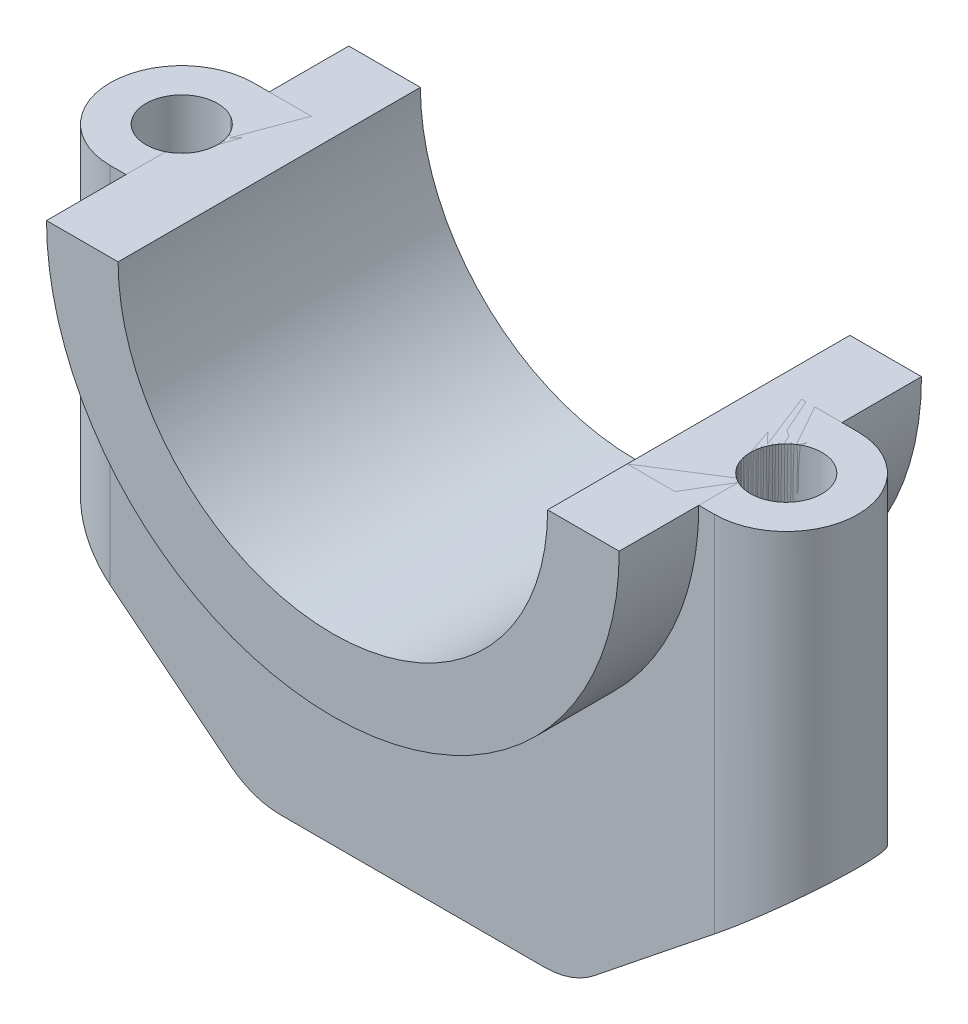
from build123d import *
from build123d.topology import SkipClean

# Parameters (mm, degrees)
BOSS_EXTRUDE1_DEPTH = 9
BOSS_EXTRUDE2_DEPTH = 19
SKETCH3_R           = 4.5
CUT_EXTRUDE1_DEPTH  = 60
CUT_EXTRUDE2_DEPTH  = 60
BOSS_EXTRUDE4_DEPTH = 60
CUT_EXTRUDE3_DEPTH  = 30
FILLET1_R           = 10


with BuildPart() as part:
    # Sketch1 → Boss-Extrude1 (new, symmetric)
    with BuildSketch(Plane.XY):
        with BuildLine():
            Line((-45.092177379, 0), (-45.092177379, -40))
            Line((-45.092177379, -40), (-20.092177379, -60))
            Line((-20.092177379, -60), (20.092177379, -60))
            Line((20.092177379, -60), (45.092177379, -40))
            Line((45.092177379, -40), (45.092177379, 0))
            Line((45.092177379, 0), (27, 0))
            ThreePointArc((27, 0), (0, -27), (-27, 0))
            Line((-27, 0), (-45.092177379, 0))
        make_face()
    extrude(amount=BOSS_EXTRUDE1_DEPTH, both=True)


with BuildPart() as body_2:
    # Sketch1_4 → Boss-Extrude2 (new, symmetric)
    with BuildSketch(Plane.XY):
        with BuildLine():
            Line((-27, 0), (-36, 0))
            ThreePointArc((-36, 0), (0, -36), (36, 0))
            Line((36, 0), (27, 0))
            ThreePointArc((27, 0), (0, -27), (-27, 0))
        make_face()
    extrude(amount=BOSS_EXTRUDE2_DEPTH, both=True)


with BuildPart() as cut_extrude1_tool:
    # Sketch3 → Cut-Extrude1 (new body)
    with BuildSketch(Plane(origin=(0, 0, 0), x_dir=(1, 0, 0), z_dir=(0, 1, 0))):
        with Locations((-38, 0)):
            Circle(SKETCH3_R)
        with Locations((38, 0)):
            Circle(SKETCH3_R)
    extrude(amount=-CUT_EXTRUDE1_DEPTH)


with BuildPart() as part_1:
    add(part.part)

    # Cut-Extrude1: cut by cut_extrude1_tool
    add(cut_extrude1_tool.part, mode=Mode.SUBTRACT)

    # Sketch3_4 → Cut-Extrude2 (cut)
    with BuildSketch(Plane(origin=(0, 0, 0), x_dir=(1, 0, 0), z_dir=(0, 1, 0))):
        with BuildLine():
            ThreePointArc((-45.092177379, 5.540850117), (-41.945399152, 8.089117722), (-38, 9))
            Line((-38, 9), (-45.092177379, 9))
            Line((-45.092177379, 9), (-45.092177379, 5.540850117))
        make_face()
        with BuildLine():
            ThreePointArc((-38, -9), (-41.945399152, -8.089117722), (-45.092177379, -5.540850117))
            Line((-45.092177379, -5.540850117), (-45.092177379, -9))
            Line((-45.092177379, -9), (-38, -9))
        make_face()
        with BuildLine():
            Line((45.092177379, 9), (38, 9))
            ThreePointArc((38, 9), (41.945399152, 8.089117722), (45.092177379, 5.540850117))
            Line((45.092177379, 5.540850117), (45.092177379, 9))
        make_face()
        with BuildLine():
            ThreePointArc((45.092177379, -5.540850117), (41.945399152, -8.089117722), (38, -9))
            Line((38, -9), (45.092177379, -9))
            Line((45.092177379, -9), (45.092177379, -5.540850117))
        make_face()
    extrude(amount=-CUT_EXTRUDE2_DEPTH, mode=Mode.SUBTRACT)

    # Sketch3_6 → Boss-Extrude4 (add)
    with SkipClean():  # the faces are left unmerged after this step: merging them gives an invalid solid
        with BuildSketch(Plane(origin=(0, 0, 0), x_dir=(1, 0, 0), z_dir=(0, 1, 0))):
            with BuildLine():
                Line((-45.092177379, -5.540850117), (-45.092177379, 5.540850117))
                ThreePointArc((-45.092177379, 5.540850117), (-47, 0), (-45.092177379, -5.540850117))
            make_face()
            with BuildLine():
                ThreePointArc((45.092177379, -5.540850117), (47, 0), (45.092177379, 5.540850117))
                Line((45.092177379, 5.540850117), (45.092177379, -5.540850117))
            make_face()
        extrude(amount=-BOSS_EXTRUDE4_DEPTH)

    # Sketch6 → Cut-Extrude3 (cut, symmetric)
    with SkipClean():  # the faces are left unmerged after this step: merging them gives an invalid solid
        with BuildSketch(Plane.XY):
            Polygon((-20.092177379, -60), (-62.463966669, -26.102568568), (-62.463966669, -60), align=None)
            Polygon((20.092177379, -60), (65.92187812, -23.336239407), (69.819094965, -60), align=None)
        extrude(amount=CUT_EXTRUDE3_DEPTH, both=True, mode=Mode.SUBTRACT)

    # Fillet1
    fillet1_edges = [part_1.edges().sort_by_distance(p)[0] for p in [
        (20.092177379, -60, 0),
        (-20.092177379, -60, 0),
    ]]
    fillet(fillet1_edges, radius=FILLET1_R)


with BuildPart() as body_2_1:
    add(body_2.part)

    # Cut-Extrude1: cut by cut_extrude1_tool
    add(cut_extrude1_tool.part, mode=Mode.SUBTRACT)


solid = Compound([part_1.part, body_2_1.part])
